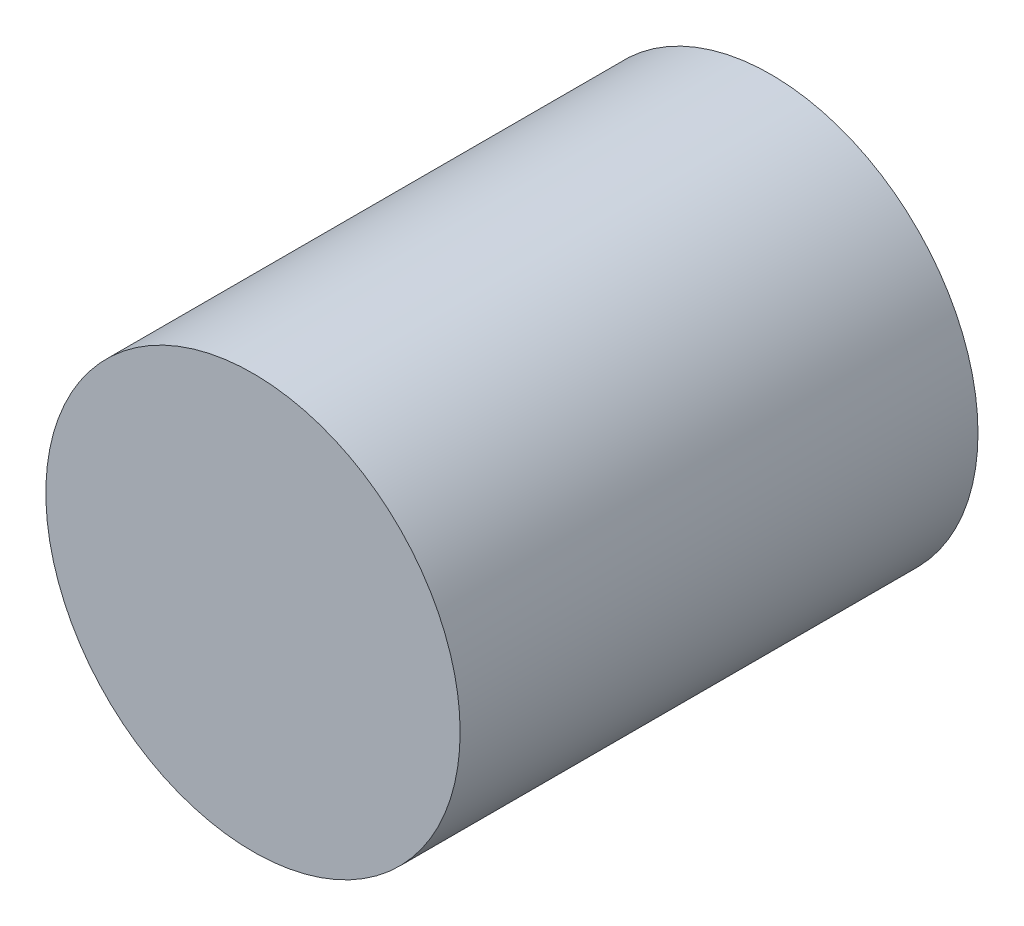
from build123d import *

# Parameters (mm, degrees)
SKETCH1_R           = 40
BOSS_EXTRUDE1_DEPTH = 100


with BuildPart() as part:
    # Sketch1 → Boss-Extrude1 (new body)
    with BuildSketch(Plane.XY):
        with Locations((-15.067024343, -8.815812116)):
            Circle(SKETCH1_R)
    extrude(amount=BOSS_EXTRUDE1_DEPTH)


solid = part.part
